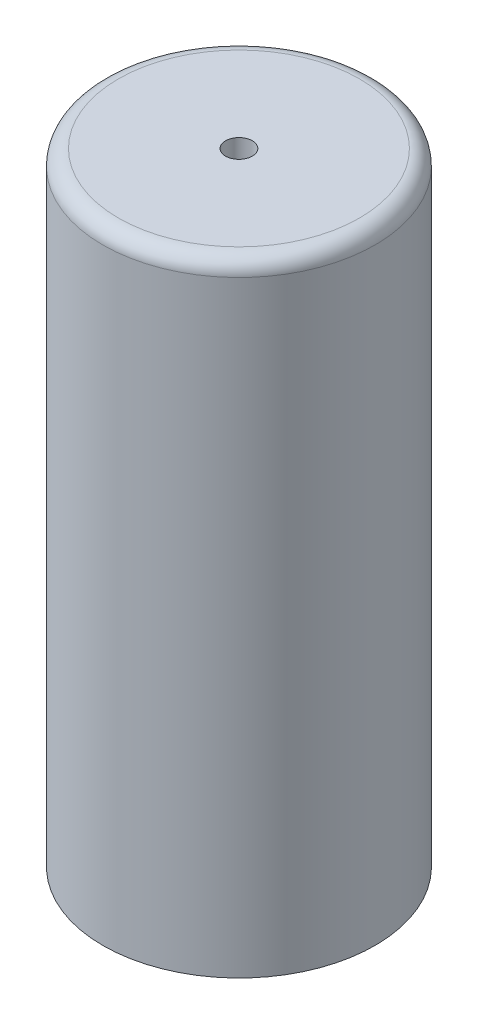
from build123d import *

# Parameters (mm, degrees)
SKETCH1_R           = 22.225
BOSS_EXTRUDE1_DEPTH = 101.6
FILLET1_R           = 2.54
SKETCH2_R           = 2.1828125
CUT_EXTRUDE1_DEPTH  = 6.858


with BuildPart() as part:
    # Sketch1 → Boss-Extrude1 (new body)
    with BuildSketch(Plane(origin=(0, 0, 0), x_dir=(1, 0, 0), z_dir=(0, 1, 0))):
        Circle(SKETCH1_R)
    extrude(amount=BOSS_EXTRUDE1_DEPTH)

    # Fillet1
    fillet1_edges = [part.edges().sort_by_distance(p)[0] for p in [
        (-22.225, 101.6, 0),
    ]]
    fillet(fillet1_edges, radius=FILLET1_R)

    # Sketch2 → Cut-Extrude1 (cut)
    with BuildSketch(Plane(origin=(0, 101.6, 0), x_dir=(1, 0, 0), z_dir=(0, 1, 0))):
        Circle(SKETCH2_R)
    extrude(amount=-CUT_EXTRUDE1_DEPTH, mode=Mode.SUBTRACT)


solid = part.part
